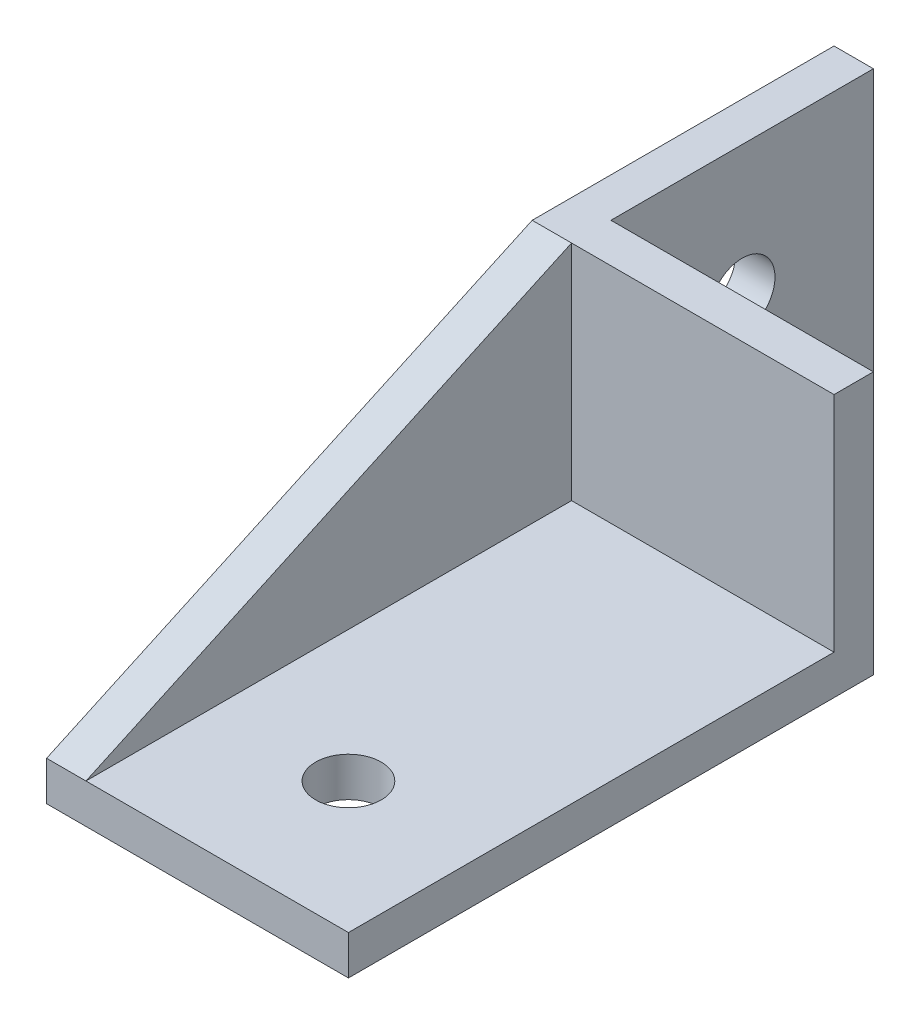
from build123d import *

# Parameters (mm, degrees)
SKETCH1_W           = 3
SKETCH1_H           = 20
BOSS_EXTRUDE1_DEPTH = 20
SKETCH3_W           = 20
SKETCH3_H           = 40
BOSS_EXTRUDE2_DEPTH = 3
BOSS_EXTRUDE3_DEPTH = 3
SKETCH5_R           = 2.5
CUT_EXTRUDE1_DEPTH  = 3
SKETCH6_R           = 2.5
CUT_EXTRUDE2_DEPTH  = 3


with BuildPart() as part:
    # Sketch1 → Boss-Extrude1 (new body)
    with BuildSketch(Plane(origin=(0, 0, 0), x_dir=(1, 0, 0), z_dir=(0, 1, 0))):
        Polygon((20, 0), (0, 0), (-3, 0), (-3, -3), (20, -3), align=None)
        with Locations((-1.5, 10)):
            Rectangle(SKETCH1_W, SKETCH1_H)
    extrude(amount=BOSS_EXTRUDE1_DEPTH)

    # Sketch3 → Boss-Extrude2 (add)
    with BuildSketch(Plane.XZ):
        with Locations((10, 20)):
            Rectangle(SKETCH3_W, SKETCH3_H)
    extrude(amount=-BOSS_EXTRUDE2_DEPTH)

    # Sketch4 → Boss-Extrude3 (add)
    with BuildSketch(Plane.ZY.offset(3)):
        Polygon((3, 20), (3, 0), (40, 0), (40, 3), align=None)
    extrude(amount=-BOSS_EXTRUDE3_DEPTH)

    # Sketch5 → Cut-Extrude1 (cut)
    with BuildSketch(Plane(origin=(0, 0, 0), x_dir=(0, 0, -1), z_dir=(1, 0, 0))):
        with Locations((10, 10)):
            Circle(SKETCH5_R)
    extrude(amount=-CUT_EXTRUDE1_DEPTH, mode=Mode.SUBTRACT)

    # Sketch6 → Cut-Extrude2 (cut)
    with BuildSketch(Plane(origin=(0, 3, 0), x_dir=(1, 0, 0), z_dir=(0, 1, 0))):
        with Locations((10, -30)):
            Circle(SKETCH6_R)
    extrude(amount=-CUT_EXTRUDE2_DEPTH, mode=Mode.SUBTRACT)


solid = part.part
